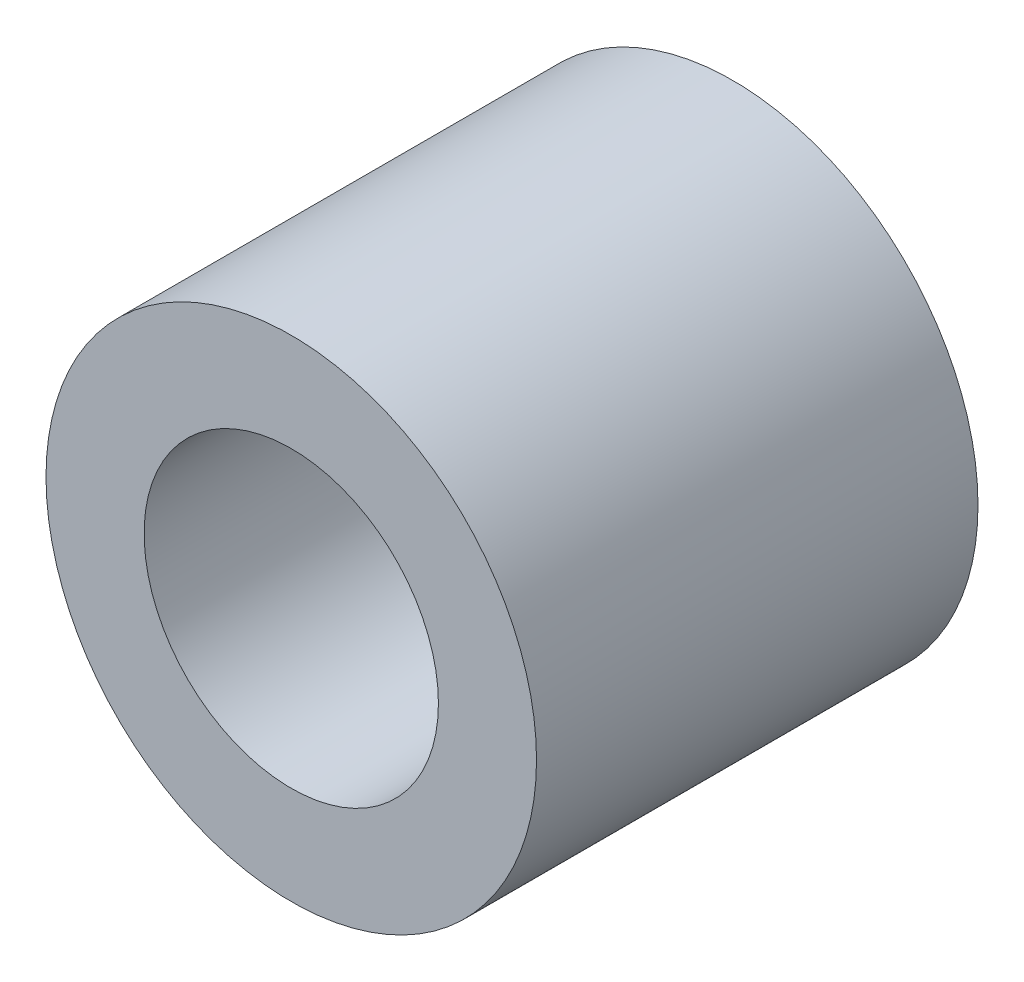
from build123d import *

# Parameters (mm, degrees)
SKETCH2_R           = 2.5
SKETCH2_R_2         = 1.5
BOSS_EXTRUDE1_DEPTH = 4.5


with BuildPart() as part:
    # Sketch2 → Boss-Extrude1 (new body)
    with BuildSketch(Plane.XY):
        Circle(SKETCH2_R)
        Circle(SKETCH2_R_2, mode=Mode.SUBTRACT)
    extrude(amount=BOSS_EXTRUDE1_DEPTH)


solid = part.part
